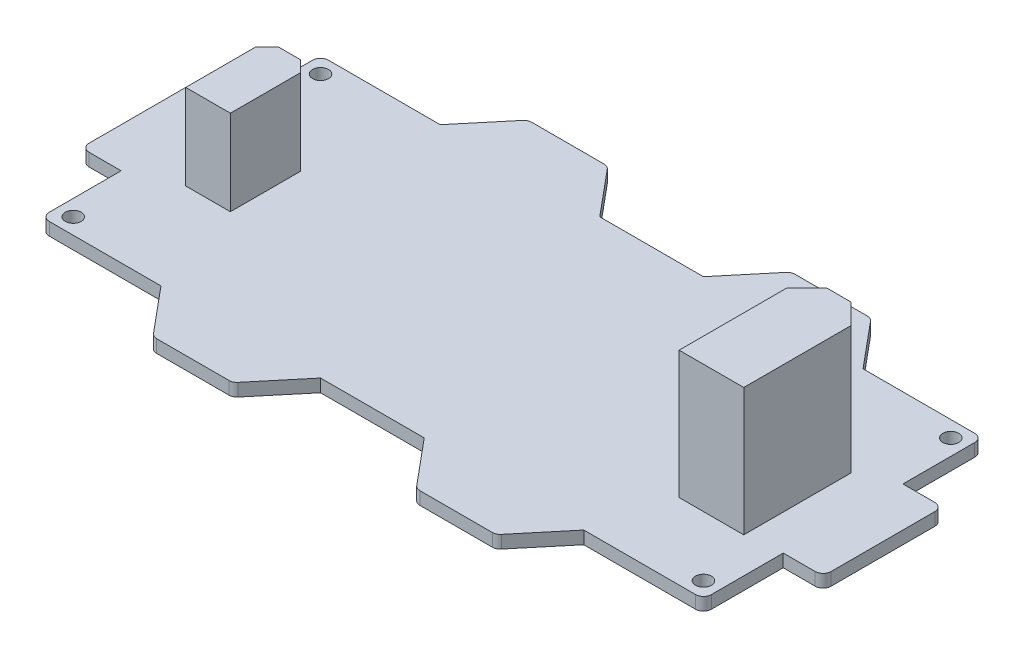
from build123d import *

# Parameters (mm, degrees)
SKETCH_1_R = 1
PCB_DEPTH  = 1.6
XT60_DEPTH = 16
XT30_DEPTH = 10.7
FILLET_2_R = 1


with BuildPart() as part:
    # 草图1 → PCB (new body)
    with BuildSketch(Plane(origin=(0, 0, 0), x_dir=(1, 0, 0), z_dir=(0, 1, 0))):
        Polygon((-26.5, 17.5), (-21.5, 23.5), (-11.5, 23.5), (-6.5, 17.5), (6.5, 17.5), (11.5, 23.5), (21.5, 23.5), (26.5, 17.5), (41.5, 17.5), (41.5, 7.5), (46.5, 7.5), (46.5, -7.5), (41.5, -7.5), (41.5, -17.5), (26.5, -17.5), (21.5, -23.5), (11.5, -23.5), (6.5, -17.5), (-6.5, -17.5), (-11.5, -23.5), (-21.5, -23.5), (-26.5, -17.5), (-41.5, -17.5), (-41.5, -7.5), (-46.5, -7.5), (-46.5, 7.5), (-41.5, 7.5), (-41.5, 17.5), align=None)
        with Locations((-39.5, 15.5)):
            Circle(SKETCH_1_R, mode=Mode.SUBTRACT)
        with Locations((-39.5, -15.5)):
            Circle(SKETCH_1_R, mode=Mode.SUBTRACT)
        with Locations((39.5, -15.5)):
            Circle(SKETCH_1_R, mode=Mode.SUBTRACT)
        with Locations((39.5, 15.5)):
            Circle(SKETCH_1_R, mode=Mode.SUBTRACT)
    extrude(amount=PCB_DEPTH)

    # 草图3 → XT60 (add)
    with BuildSketch(Plane(origin=(0, 1.6, 0), x_dir=(1, 0, 0), z_dir=(0, 1, 0))):
        Polygon((28.95, 5.45), (31.5, 8), (34.5, 8), (37.05, 5.45), (37.05, -8), (28.95, -8), align=None)
    extrude(amount=XT60_DEPTH)

    # 草图4 → XT30 (add)
    with BuildSketch(Plane(origin=(0, 1.6, 0), x_dir=(1, 0, 0), z_dir=(0, 1, 0))):
        Polygon((-34.4, 5.1), (-35.8, 3.7), (-35.8, -5.1), (-30.2, -5.1), (-30.2, 3.7), (-31.6, 5.1), align=None)
    extrude(amount=XT30_DEPTH)

    # 圆角2
    fillet_2_edges = [part.edges().sort_by_distance(p)[0] for p in [
        (46.5, 0.8, -7.5),
        (46.5, 0.8, 7.5),
        (41.5, 0.8, 17.5),
        (21.5, 0.8, 23.5),
        (11.5, 0.8, 23.5),
        (-11.5, 0.8, 23.5),
        (-21.5, 0.8, 23.5),
        (-41.5, 0.8, 17.5),
        (-46.5, 0.8, 7.5),
        (-46.5, 0.8, -7.5),
        (-41.5, 0.8, -17.5),
        (-21.5, 0.8, -23.5),
        (-11.5, 0.8, -23.5),
        (11.5, 0.8, -23.5),
        (21.5, 0.8, -23.5),
        (41.5, 0.8, -17.5),
    ]]
    fillet(fillet_2_edges, radius=FILLET_2_R)


solid = part.part
